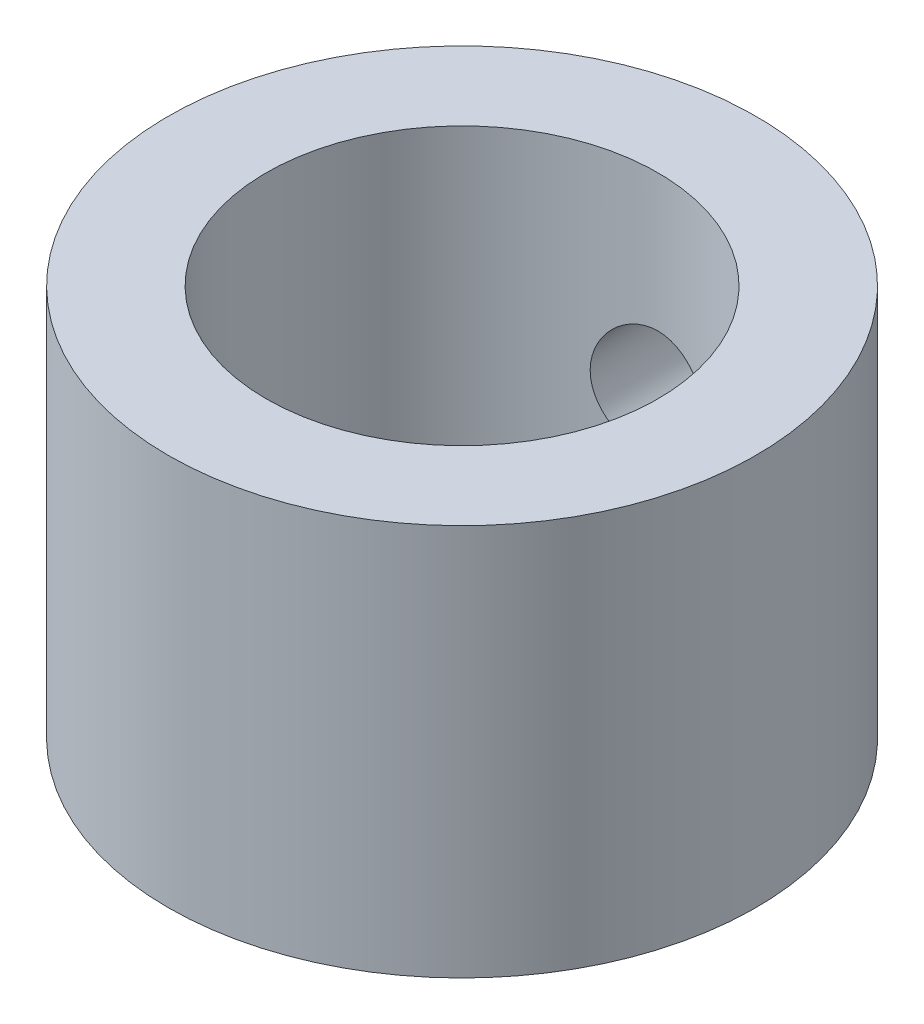
from build123d import *

# Parameters (mm, degrees)
SKETCH1_R           = 7.5
SKETCH1_R_2         = 5
BOSS_EXTRUDE1_DEPTH = 5
CUT_EXTRUDE1_REACH  = 9.5
SKETCH5_R           = 1.5


with BuildPart() as part:
    # Sketch1 → Boss-Extrude1 (new body, symmetric)
    with BuildSketch(Plane(origin=(0, 0, 0), x_dir=(1, 0, 0), z_dir=(0, 1, 0))):
        Circle(SKETCH1_R)
        Circle(SKETCH1_R_2, mode=Mode.SUBTRACT)
    extrude(amount=BOSS_EXTRUDE1_DEPTH, both=True)

    # Sketch5 → Cut-Extrude1 (cut, up to next)
    with BuildSketch(Plane.XY, mode=Mode.PRIVATE) as cut_extrude1_sk1:
        Circle(SKETCH5_R)
    cut_extrude1_tool1 = extrude(cut_extrude1_sk1.sketch, amount=-CUT_EXTRUDE1_REACH, mode=Mode.PRIVATE) & part.part
    add(cut_extrude1_tool1.solids().sort_by_distance((0, 0, 0))[0], mode=Mode.SUBTRACT)


solid = part.part
